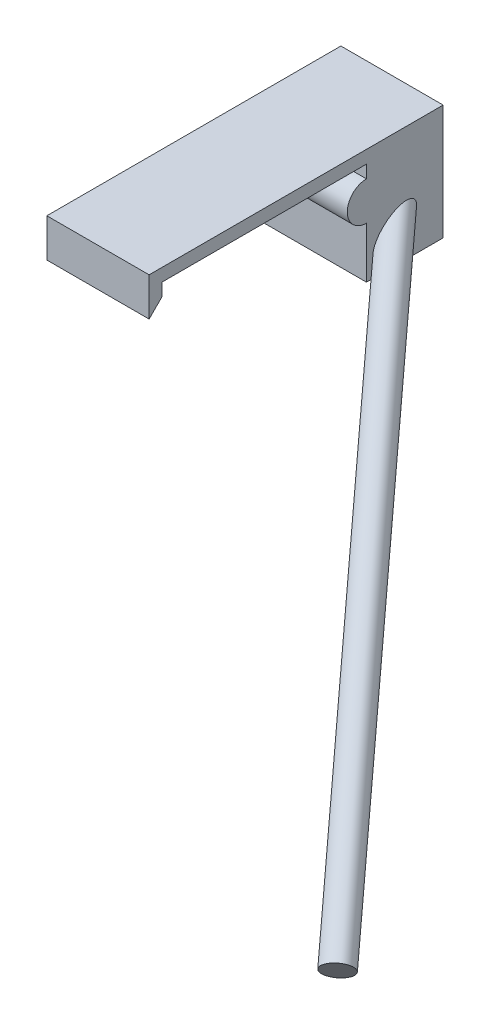
from build123d import *

# Parameters (mm, degrees)
SKETCH1_W                  = 38.1
SKETCH1_H                  = 50.8
BOSS_EXTRUDE1_DEPTH        = 3.175
SKETCH2_W                  = 38.1
SKETCH2_H                  = 19.05
BOSS_EXTRUDE2_DEPTH        = 28.575
SKETCH4_2_R                = 3.4925
IMAGINARYTUBING_DEPTH      = 12.7
IMAGINARYTUBING_DEPTH_BACK = 152.4
CUT_EXTRUDE1_DEPTH         = 12.7
SKETCH7_W                  = 25.4
SKETCH7_H                  = 9.525
BOSS_EXTRUDE4_DEPTH        = 3.175
BOSS_EXTRUDE5_DEPTH        = 25.4
CUT_EXTRUDE2_DEPTH         = 25.4


with BuildPart() as part:
    # Sketch1 → Boss-Extrude1 (new body)
    with BuildSketch(Plane(origin=(0, 0, 0), x_dir=(1, 0, 0), z_dir=(0, 1, 0))):
        Rectangle(SKETCH1_W, SKETCH1_H)
    extrude(amount=BOSS_EXTRUDE1_DEPTH)

    # Sketch2 → Boss-Extrude2 (add)
    with BuildSketch(Plane(origin=(0, 3.175, 0), x_dir=(1, 0, 0), z_dir=(0, 1, 0))):
        with Locations((0, 34.925)):
            Rectangle(SKETCH2_W, SKETCH2_H)
    extrude(amount=-BOSS_EXTRUDE2_DEPTH)

    # Sketch4_2 → ImaginaryTubing (add, two sides)
    with BuildSketch(Plane(origin=(-6.98065937, 6.98065937, -8.283711681), x_dir=(0.707106781, 0.707106781, 0), z_dir=(-0.54167522, 0.54167522, -0.64278761))) as imaginarytubing_sk:
        with Locations((0.967560903, 41.541493051)):
            Circle(SKETCH4_2_R)
    extrude(amount=IMAGINARYTUBING_DEPTH)
    extrude(imaginarytubing_sk.sketch, amount=-IMAGINARYTUBING_DEPTH_BACK)

    # Sketch6 → Cut-Extrude1 (cut)
    with BuildSketch(Plane.ZY.offset(19.05)):
        Polygon((-25.4, 0), (25.4, 0), (25.4, 3.175), (-44.45, 3.175), (-44.45, -25.4), (-25.4, -25.4), align=None)
    extrude(amount=-CUT_EXTRUDE1_DEPTH, mode=Mode.SUBTRACT)

    # Sketch7 → Boss-Extrude4 (add)
    with BuildSketch(Plane.XY.offset(25.4)):
        with Locations((6.35, -1.5875)):
            Rectangle(SKETCH7_W, SKETCH7_H)
    extrude(amount=BOSS_EXTRUDE4_DEPTH)

    # Sketch8 → Boss-Extrude5 (add)
    with BuildSketch(Plane(origin=(19.05, 0, 0), x_dir=(0, 0, -1), z_dir=(1, 0, 0))):
        with BuildLine():
            Line((25.4, -12.7), (25.4, -3.175))
            ThreePointArc((25.4, -3.175), (20.6375, -7.9375), (25.4, -12.7))
        make_face()
    extrude(amount=-BOSS_EXTRUDE5_DEPTH)

    # Sketch11 → Cut-Extrude2 (cut)
    with BuildSketch(Plane(origin=(19.05, 0, 0), x_dir=(0, 0, -1), z_dir=(1, 0, 0))):
        Polygon((-25.4, -3.175), (-28.575, -6.35), (-25.4, -6.35), align=None)
    extrude(amount=-CUT_EXTRUDE2_DEPTH, mode=Mode.SUBTRACT)


solid = part.part
